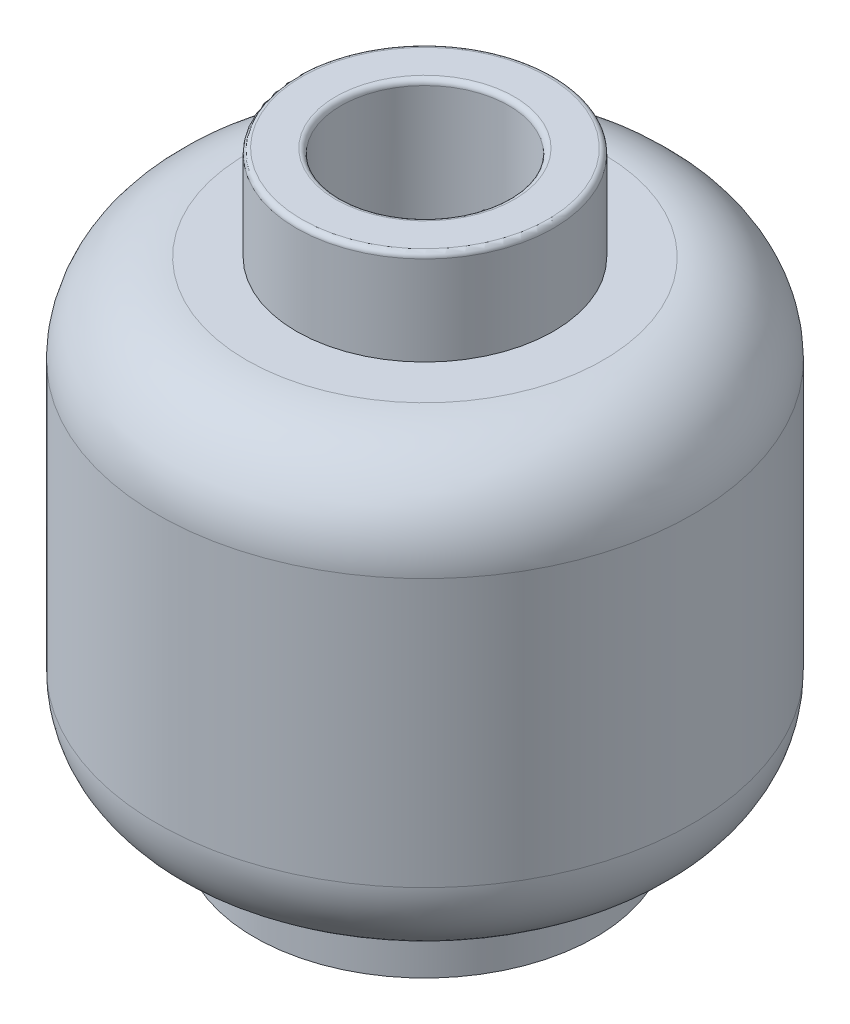
from build123d import *

# Parameters (mm, degrees)
CROQUIS3_R            = 1.6
CORTAR_EXTRUIR1_DEPTH = 2
CORTAR_EXTRUIR2_DEPTH = 0.9
MATRIZC1_COUNT        = 3
REDONDEO1_R           = 0.1


with BuildPart() as part:
    # Croquis1 → Revolución1 (revolve)
    with BuildSketch(Plane(origin=(0, 0, 0), x_dir=(0, 0, -1), z_dir=(1, 0, 0))):
        with BuildLine():
            Line((2.45, 0), (3.25, 0))
            Line((3.25, 0), (3.25, 1.1))
            Line((3.25, 1.1), (3.4, 1.1))
            ThreePointArc((3.4, 1.1), (4.602082, 1.597918), (5.1, 2.8))
            Line((5.1, 2.8), (5.1, 7.9))
            ThreePointArc((5.1, 7.9), (4.602082, 9.102082), (3.4, 9.6))
            Line((3.4, 9.6), (2.45, 9.6))
            Line((2.45, 9.6), (2.45, 11.4))
            Line((2.45, 11.4), (0, 11.4))
            Line((0, 11.4), (0, 8.5))
            Line((0, 8.5), (2.45, 8.5))
            Line((2.45, 8.5), (2.45, 0))
        make_face()
    revolve(axis=Axis((0, 0, 0), (0, 1, 0)))

    # Croquis3 → Cortar-Extruir1 (cut)
    with BuildSketch(Plane(origin=(0, 11.4, 0), x_dir=(1, 0, 0), z_dir=(0, 1, 0))):
        Circle(CROQUIS3_R)
    extrude(amount=-CORTAR_EXTRUIR1_DEPTH, mode=Mode.SUBTRACT)

    # Croquis4 → Cortar-Extruir2 (cut)
    with BuildSketch(Plane(origin=(0, 9.4, 0), x_dir=(1, 0, 0), z_dir=(0, 1, 0))):
        with BuildLine():
            Line((-1.547049, -0.408215), (-0.42, 0.242487))
            Line((-0.42, 0.242487), (-0.42, 1.543891))
            ThreePointArc((-0.42, 1.543891), (-1.385641, 0.8), (-1.547049, -0.408215))
        make_face()
    cortar_extruir2 = extrude(amount=-CORTAR_EXTRUIR2_DEPTH, mode=Mode.SUBTRACT)

    # MatrizC1: Cortar-Extruir2 ×3 about axis
    matrizc1_axis = Axis((0, 0, 0), (0, 1, 0))
    for i in range(1, MATRIZC1_COUNT):
        add(cortar_extruir2.rotate(matrizc1_axis, i * 360 / MATRIZC1_COUNT), mode=Mode.SUBTRACT)

    # Redondeo1
    redondeo1_edges = [part.edges().sort_by_distance(p)[0] for p in [
        (-1.6, 11.4, 0),
        (0, 11.4, 2.45),
    ]]
    fillet(redondeo1_edges, radius=REDONDEO1_R)


solid = part.part
